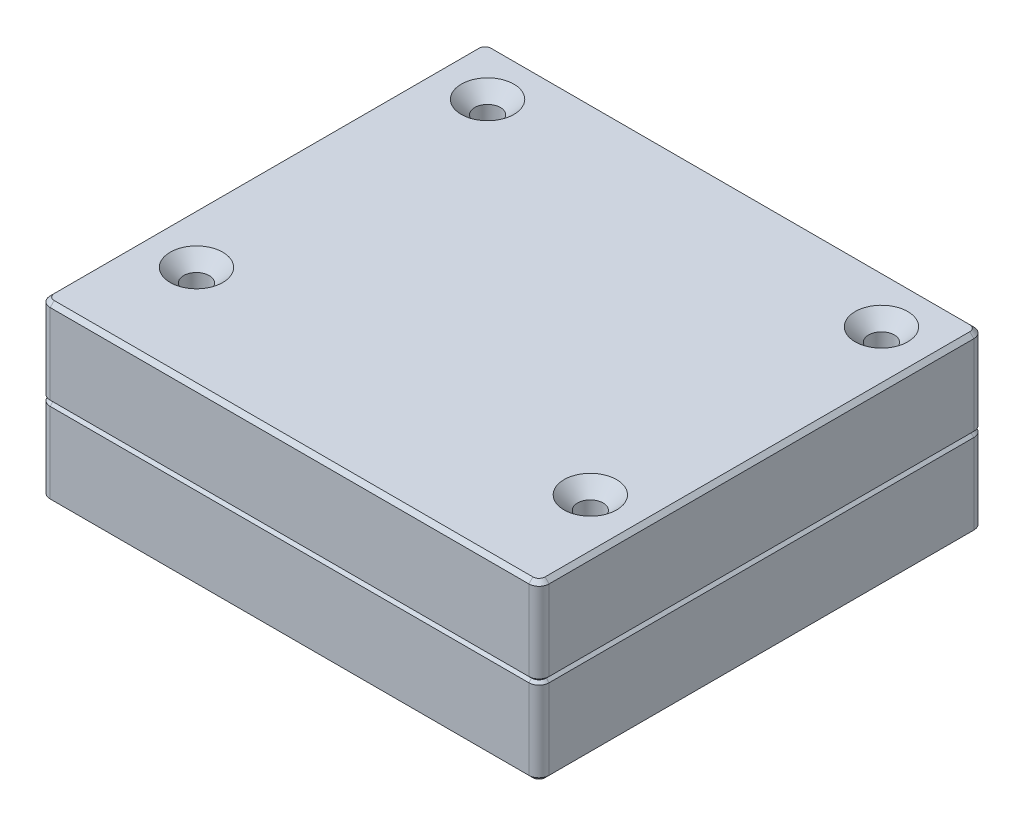
from build123d import *

# Parameters (mm, degrees)
BOSS_EXTRUDE1_DEPTH             = 2
BOSS_EXTRUDE2_DEPTH             = 1
BOSS_EXTRUDE4_START             = -2
BOSS_EXTRUDE4_DEPTH             = 1
SKETCH3_W                       = 70
SKETCH3_H                       = 64
BOSS_EXTRUDE5_DEPTH             = 2
BOSS_EXTRUDE6_REACH             = 74.888
BOSS_EXTRUDE6_DIRECTION_2_REACH = 74.888
SKETCH5_W                       = 15.58
SKETCH5_H                       = 6.82
SKETCH5_R                       = 1.4
BOSS_EXTRUDE8_DEPTH             = 9.996248688
FILLET1_R                       = 3
FILLET2_R                       = 2
FILLET4_R                       = 2
FILLET5_R                       = 1
FILLET6_R                       = 1.5
CHAMFER1_SIZE                   = 0.6
FILLET7_R                       = 1
CUT_EXTRUDE1_DEPTH              = 0.2
CUT_EXTRUDE2_DEPTH              = 0.2
SKETCH9_R                       = 1.9
CUT_EXTRUDE3_DEPTH              = 77.054825474
CHAMFER2_SIZE                   = 2
CHAMFER3_SIZE                   = 0.8
CHAMFER4_SIZE                   = 0.8
CHAMFER5_SIZE                   = 0.4
CHAMFER6_SIZE                   = 0.4


with BuildPart() as part:
    # Sketch1 → Boss-Extrude1 (new body)
    with BuildSketch(Plane.XY):
        Polygon((17.693293109, 0), (20.693293109, 0), (20.693293109, -10.896248688), (-20.693293109, -10.896248688), (-20.693293109, 0), (-17.693293109, 0), (-17.693293109, -9.896248688), (17.693293109, -9.896248688), align=None)
    extrude(amount=BOSS_EXTRUDE1_DEPTH)

    # Sketch2 → Boss-Extrude2 (add)
    with BuildSketch(Plane.XY.offset(2)):
        Polygon((-17.693293109, 0), (-16.693293109, 0), (-16.693293109, -8.896248688), (16.693293109, -8.896248688), (16.693293109, 0), (17.693293109, 0), (20.693293109, 0), (20.693293109, -10.896248688), (-20.693293109, -10.896248688), (-20.693293109, 0), align=None)
    extrude(amount=BOSS_EXTRUDE2_DEPTH)

    # Sketch2_3 → Boss-Extrude4 (add)
    with BuildSketch(Plane.XY.offset(2).offset(BOSS_EXTRUDE4_START)):
        Polygon((-16.693293109, 0), (-17.693293109, 0), (-17.693293109, -9.896248688), (17.693293109, -9.896248688), (17.693293109, 0), (16.693293109, 0), (16.693293109, -8.896248688), (-16.693293109, -8.896248688), align=None)
        Polygon((-17.693293109, -9.896248688), (-17.693293109, 0), (-20.693293109, 0), (-20.693293109, -10.896248688), (20.693293109, -10.896248688), (20.693293109, 0), (17.693293109, 0), (17.693293109, -9.896248688), align=None)
    extrude(amount=-BOSS_EXTRUDE4_DEPTH)

    # Sketch3 → Boss-Extrude5 (add)
    with BuildSketch(Plane.XZ.offset(10.896248688)):
        with Locations((0, 31)):
            Rectangle(SKETCH3_W, SKETCH3_H)
    extrude(amount=BOSS_EXTRUDE5_DEPTH)

    # Boss-Extrude6: up to this face of the body (flat: up to its plane)
    boss_extrude6_end = Plane(part.part.faces().sort_by_distance((18.907578824, 0, 1))[0])
    # Sketch4 → Boss-Extrude6 (add, up to the picked face)
    with BuildSketch(Plane(origin=(0, -10.896248688, 0), x_dir=(1, 0, 0), z_dir=(0, 1, 0)), mode=Mode.PRIVATE) as boss_extrude6_sk1:
        Polygon((20.693293109, 1), (37, 1), (37, -65), (-37, -65), (-37, 1), (-20.693293109, 1), (-20.693293109, -3), (-35, -3), (-35, -63), (35, -63), (35, -3), (20.693293109, -3), align=None)
    boss_extrude6_tool1 = split(extrude(boss_extrude6_sk1.sketch, amount=BOSS_EXTRUDE6_REACH, mode=Mode.PRIVATE), bisect_by=boss_extrude6_end, keep=Keep.BOTH, mode=Mode.PRIVATE)
    add(boss_extrude6_tool1.solids().sort_by(Axis((28.846647, -10.896249, -0.008436), (0, 1, 0)))[0])

    # Boss-Extrude6 direction 2: up to this face of the body (flat: up to its plane)
    boss_extrude6_direction_2_end = Plane(part.part.faces().sort_by_distance((0, -12.896248688, 31))[0])
    # Sketch4 → Boss-Extrude6 direction 2 (add, up to the picked face)
    with BuildSketch(Plane(origin=(0, -10.896248688, 0), x_dir=(1, 0, 0), z_dir=(0, 1, 0)), mode=Mode.PRIVATE) as boss_extrude6_direction_2_sk1:
        Polygon((20.693293109, 1), (37, 1), (37, -65), (-37, -65), (-37, 1), (-20.693293109, 1), (-20.693293109, -3), (-35, -3), (-35, -63), (35, -63), (35, -3), (20.693293109, -3), align=None)
    boss_extrude6_direction_2_tool1 = split(extrude(boss_extrude6_direction_2_sk1.sketch, amount=-BOSS_EXTRUDE6_DIRECTION_2_REACH, mode=Mode.PRIVATE), bisect_by=boss_extrude6_direction_2_end, keep=Keep.BOTH, mode=Mode.PRIVATE)
    add(boss_extrude6_direction_2_tool1.solids().sort_by(Axis((28.846647, -10.896249, -0.008436), (0, -1, 0)))[0])

    # Sketch5 → Boss-Extrude8 (add)
    with BuildSketch(Plane(origin=(0, -10.896248688, 0), x_dir=(1, 0, 0), z_dir=(0, 1, 0))):
        with Locations((29.21, -6.41)):
            Rectangle(SKETCH5_W, SKETCH5_H)
        with Locations((29.21, -6.41)):
            Circle(SKETCH5_R, mode=Mode.SUBTRACT)
        with Locations((29.21, -49.59)):
            Rectangle(SKETCH5_W, SKETCH5_H)
        with Locations((29.21, -49.59)):
            Circle(SKETCH5_R, mode=Mode.SUBTRACT)
    boss_extrude8 = extrude(amount=BOSS_EXTRUDE8_DEPTH)

    # Mirror3: Boss-Extrude8 across plane
    add(boss_extrude8.mirror(Plane(origin=(0, 0, 0), x_dir=(0, 0, 1), z_dir=(1, 0, 0))))

    # Fillet1
    fillet1_edges = [part.edges().sort_by_distance(p)[0] for p in [
        (21.42, -5.898124344, 9.82),
        (21.42, -5.898124344, 53),
        (21.42, -5.898124344, 46.18),
        (-21.42, -5.898124344, 9.82),
        (-21.42, -5.898124344, 46.18),
        (-21.42, -5.898124344, 53),
    ]]
    fillet(fillet1_edges, radius=FILLET1_R)

    # Fillet2
    fillet2_edges = [part.edges().sort_by_distance(p)[0] for p in [
        (35, -5.898124344, 9.82),
        (35, -5.898124344, 46.18),
        (35, -5.898124344, 53),
        (-35, -5.898124344, 9.82),
        (-35, -5.898124344, 46.18),
        (-35, -5.898124344, 53),
    ]]
    fillet(fillet2_edges, radius=FILLET2_R)

    # Fillet4
    fillet4_edges = [part.edges().sort_by_distance(p)[0] for p in [
        (-35, -5.448124344, 63),
        (35, -5.448124344, 63),
    ]]
    fillet(fillet4_edges, radius=FILLET4_R)

    # Fillet5
    fillet5_edges = [part.edges().sort_by_distance(p)[0] for p in [
        (16.693293109, -8.896248688, 2.5),
        (-16.693293109, -8.896248688, 2.5),
        (-16.693293109, -8.896248688, -0.5),
        (16.693293109, -8.896248688, -0.5),
    ]]
    fillet(fillet5_edges, radius=FILLET5_R)

    # Fillet6
    fillet6_edges = [part.edges().sort_by_distance(p)[0] for p in [
        (37, -6.448124344, -1),
        (37, -6.448124344, 65),
        (-37, -6.448124344, 65),
        (-37, -6.448124344, -1),
    ]]
    fillet(fillet6_edges, radius=FILLET6_R)

    # Chamfer1
    chamfer1_edges = [part.edges().sort_by_distance(p)[0] for p in [
        (0, -12.896248688, -1),
        (-37, -12.896248688, 32),
        (37, -12.896248688, 32),
        (0, -12.896248688, 65),
        (-36.560660172, -12.896248688, -0.560660172),
        (-36.560660172, -12.896248688, 64.560660172),
        (36.560660172, -12.896248688, 64.560660172),
        (36.560660172, -12.896248688, -0.560660172),
    ]]
    chamfer(chamfer1_edges, length=CHAMFER1_SIZE)

    # Fillet7
    fillet7_edges = [part.edges().sort_by_distance(p)[0] for p in [
        (21.42, -10.896248688, 4.91),
        (-21.42, -10.896248688, 4.91),
        (-28.71, -10.896248688, 9.82),
        (-21.42, -10.896248688, 49.59),
        (-28.71, -10.896248688, 53),
        (28.71, -10.896248688, 9.82),
        (28.71, -10.896248688, 53),
        (21.42, -10.896248688, 49.59),
        (-22.298679656, -10.896248688, 8.941320344),
        (-22.298679656, -10.896248688, 52.121320344),
        (-22.298679656, -10.896248688, 47.058679656),
        (22.298679656, -10.896248688, 8.941320344),
        (22.298679656, -10.896248688, 52.121320344),
        (22.298679656, -10.896248688, 47.058679656),
        (-35, -10.896248688, 28),
        (-28.71, -10.896248688, 46.18),
        (35, -10.896248688, 58),
        (28.71, -10.896248688, 46.18),
        (35, -10.896248688, 28),
        (34.414213562, -10.896248688, 10.405786438),
        (34.414213562, -10.896248688, 45.594213562),
        (34.414213562, -10.896248688, 53.585786438),
        (-34.414213562, -10.896248688, 10.405786438),
        (-34.414213562, -10.896248688, 45.594213562),
        (-34.414213562, -10.896248688, 53.585786438),
        (-35, -10.896248688, 58),
        (0, -10.896248688, 63),
        (34.414213562, -10.896248688, 62.414213562),
        (-34.414213562, -10.896248688, 62.414213562),
    ]]
    fillet(fillet7_edges, radius=FILLET7_R)


with BuildPart() as body_2:
    # Mirror4: mirrored copy
    add(part.part.mirror(Plane.ZX))

    # Sketch8 → Cut-Extrude2 (cut)
    with BuildSketch(Plane.XZ.offset(-10.896248688)):
        Polygon((-17.856905846, 13.437302516), (-17.856905846, 16.668071747), (-16.77998277, 16.668071747), (-16.77998277, 15.59114867), (-11.856905846, 15.59114867), (-11.856905846, 14.514225593), (-16.77998277, 14.514225593), (-16.77998277, 13.437302516), align=None)
        with BuildLine():
            add(Edge.make_bspline(
                [(-18.010752, 21.603167901), (-18.008050512, 21.707484931), (-18.002717161, 21.913430376), (-17.958275747, 22.216307404), (-17.885824456, 22.508163693), (-17.785254831, 22.788970316), (-17.653307909, 23.0574515), (-17.496033953, 23.316223934), (-17.306596788, 23.562010122), (-17.091743359, 23.793960914), (-16.857947533, 24.008257244), (-16.606233441, 24.19389776), (-16.34291732, 24.352639042), (-16.06700126, 24.483233398), (-15.777544563, 24.583547586), (-15.475753411, 24.65363426), (-15.161546068, 24.698718975), (-14.947607117, 24.703900089), (-14.838877, 24.706533285)],
                knots=[0, 0, 0, 0, 1.014235534, 2.002330665, 2.970116157, 3.9352621, 4.897279957, 5.875024536, 6.875755618, 7.909865842, 8.947091691, 9.955591861, 10.946663836, 11.933282567, 12.91916997, 13.920121047, 14.942943865, 16, 16, 16, 16], degree=3))
            add(Edge.make_bspline(
                [(-14.838877, 24.706533285), (-14.731372357, 24.703728135), (-14.519531007, 24.698200496), (-14.208214407, 24.655483535), (-13.909673698, 24.584171783), (-13.623302062, 24.485832125), (-13.350543528, 24.357378178), (-13.090259563, 24.201352816), (-12.843342843, 24.016112425), (-12.610833804, 23.806095379), (-12.398346893, 23.576316348), (-12.21231631, 23.331582559), (-12.054717653, 23.074810639), (-11.924936358, 22.80620169), (-11.827035463, 22.523820109), (-11.753826534, 22.230853406), (-11.711477209, 21.924918773), (-11.70589375, 21.717077578), (-11.703059693, 21.611581362)],
                knots=[0, 0, 0, 0, 1.051628416, 2.072267533, 3.067761847, 4.050852917, 5.029392597, 6.012272624, 7.015026456, 8.044749159, 9.073964344, 10.072810436, 11.047668484, 12.017263184, 12.98554948, 13.966731695, 14.967951888, 16, 16, 16, 16], degree=3))
            add(Edge.make_bspline(
                [(-11.703059693, 21.611581362), (-11.705572491, 21.501236656), (-11.710509798, 21.28442439), (-11.757065253, 20.967039905), (-11.828045244, 20.663391525), (-11.930807193, 20.374311255), (-12.064332038, 20.100023822), (-12.225553099, 19.839299163), (-12.417584582, 19.594098159), (-12.634634491, 19.365238138), (-12.87219629, 19.157914557), (-13.12314328, 18.974904518), (-13.385577697, 18.820533075), (-13.659617354, 18.694792298), (-13.943560469, 18.595663425), (-14.23913599, 18.525739242), (-14.545635114, 18.484433365), (-14.753815442, 18.478679695), (-14.859309693, 18.475764055)],
                knots=[0, 0, 0, 0, 1.067953136, 2.098381936, 3.099641766, 4.083805132, 5.062469929, 6.048665414, 7.046702845, 8.073106546, 9.098695993, 10.09591865, 11.076726721, 12.041940862, 13.011263376, 13.984305721, 14.978557872, 16, 16, 16, 16], degree=3))
            add(Edge.make_bspline(
                [(-14.859309693, 18.475764055), (-14.9302806, 18.476679418), (-15.071323759, 18.478498555), (-15.280344328, 18.500401634), (-15.485278024, 18.531956053), (-15.685341068, 18.578548042), (-15.882181674, 18.6355154), (-16.074046211, 18.708357935), (-16.262235824, 18.792340607), (-16.444641289, 18.889440532), (-16.619161572, 18.999212413), (-16.787297002, 19.11643751), (-16.94464736, 19.245579419), (-17.092890877, 19.383998884), (-17.231459708, 19.532158592), (-17.360209812, 19.690357225), (-17.480614714, 19.857458479), (-17.591075987, 20.033477718), (-17.688717297, 20.217113033), (-17.776155603, 20.404312192), (-17.847934677, 20.595853118), (-17.907032894, 20.790613298), (-17.954525483, 20.988317482), (-17.986089046, 21.190537055), (-18.007983411, 21.395553289), (-18.009826947, 21.533798793), (-18.010752, 21.603167901)],
                knots=[0, 0, 0, 0, 1.034634222, 2.056167603, 3.061938024, 4.056975325, 5.049831446, 6.048294015, 7.047371884, 8.053753139, 9.058980286, 10.052730068, 11.041053953, 12.024946181, 13.008838409, 13.997162294, 14.997691456, 16.01096975, 17.025258359, 18.029177048, 19.022170708, 20.005507574, 20.996177714, 21.984639769, 22.988728483, 24, 24, 24, 24], degree=3))
        make_face()
        with BuildLine():
            add(Edge.make_bspline(
                [(-16.933828923, 21.586340978), (-16.93194515, 21.516135413), (-16.928227337, 21.377577721), (-16.899902623, 21.174338821), (-16.854664835, 20.9792223), (-16.789138452, 20.793309765), (-16.705739998, 20.615795456), (-16.604760876, 20.446364694), (-16.482730042, 20.287363746), (-16.346198787, 20.136672487), (-16.194071593, 20.000547731), (-16.031041432, 19.880277215), (-15.857380563, 19.779630165), (-15.674702254, 19.69533763), (-15.480952335, 19.631884033), (-15.27764847, 19.586687939), (-15.064440358, 19.558125694), (-14.919096665, 19.554525388), (-14.844886616, 19.552687132)],
                knots=[0, 0, 0, 0, 1.033739768, 2.040188636, 3.016340934, 3.979330865, 4.937572243, 5.900995986, 6.878200029, 7.884839167, 8.891893314, 9.879764717, 10.863503415, 11.843163062, 12.837761627, 13.859916423, 14.907309254, 16, 16, 16, 16], degree=3))
            add(Edge.make_bspline(
                [(-14.844886616, 19.552687132), (-14.762647564, 19.555129971), (-14.601472648, 19.559917531), (-14.366314821, 19.593447637), (-14.144021802, 19.651325762), (-13.935697322, 19.73340453), (-13.74016809, 19.83743132), (-13.55853596, 19.964849558), (-13.389946766, 20.115638655), (-13.291491535, 20.231740947), (-13.241521231, 20.290667901)],
                knots=[0, 0, 0, 0, 1.078420897, 2.113526272, 3.107597235, 4.084297302, 5.043369457, 6.005430726, 6.9876695, 8, 8, 8, 8], degree=3))
            add(Edge.make_bspline(
                [(-13.241521231, 20.290667901), (-13.204606935, 20.338944378), (-13.131610028, 20.434409656), (-13.038049517, 20.586793024), (-12.957858825, 20.743717887), (-12.893065695, 20.90636844), (-12.842100508, 21.074401174), (-12.806410426, 21.247793045), (-12.784011813, 21.426298374), (-12.781334754, 21.547012043), (-12.77998277, 21.607975593)],
                knots=[0, 0, 0, 0, 1.023928204, 2.024787132, 3.009472467, 3.9914905, 4.972207045, 5.96565515, 6.972602802, 8, 8, 8, 8], degree=3))
            add(Edge.make_bspline(
                [(-12.77998277, 21.607975593), (-12.781885311, 21.676972559), (-12.78562862, 21.812726259), (-12.813564716, 22.012201934), (-12.861057115, 22.203212134), (-12.925524012, 22.387550617), (-13.012017908, 22.562662362), (-13.114201901, 22.731333074), (-13.237025077, 22.890622294), (-13.376433164, 23.040471874), (-13.529094947, 23.177918646), (-13.69217866, 23.299172658), (-13.86416685, 23.401475359), (-14.045031066, 23.485125132), (-14.234572538, 23.550650573), (-14.433371897, 23.595389356), (-14.640523401, 23.624169329), (-14.781487599, 23.627773903), (-14.853300077, 23.629610208)],
                knots=[0, 0, 0, 0, 1.026460056, 2.019592442, 2.989754624, 3.951362471, 4.919177453, 5.890456226, 6.881277895, 7.906300149, 8.932084862, 9.933608786, 10.925308803, 11.904168404, 12.893913482, 13.903284022, 14.931853825, 16, 16, 16, 16], degree=3))
            add(Edge.make_bspline(
                [(-14.853300077, 23.629610208), (-14.924702226, 23.627716893), (-15.065246467, 23.623990191), (-15.271828065, 23.595896132), (-15.469517635, 23.549190715), (-15.658824769, 23.483181033), (-15.840743315, 23.400946705), (-16.013694377, 23.297646699), (-16.177528322, 23.175520094), (-16.331271136, 23.036799466), (-16.472560404, 22.885835426), (-16.595171393, 22.723753897), (-16.70171707, 22.555097857), (-16.785180501, 22.375995484), (-16.851675679, 22.19011159), (-16.900643672, 21.99631176), (-16.928028354, 21.793862003), (-16.931878165, 21.656131246), (-16.933828923, 21.586340978)],
                knots=[0, 0, 0, 0, 1.055040155, 2.076685641, 3.074845078, 4.052329834, 5.035358467, 6.020382375, 7.023447318, 8.050688466, 9.077178457, 10.074336316, 11.0503314, 12.019748348, 12.988025369, 13.964577102, 14.968620271, 16, 16, 16, 16], degree=3))
        make_face(mode=Mode.SUBTRACT)
        with BuildLine():
            Line((-17.856905846, 27.052687132), (-17.856905846, 28.254610208))
            add(Edge.make_bspline(
                [(-17.856905846, 28.254610208), (-17.856554321, 28.333142304), (-17.855876154, 28.484647176), (-17.847652456, 28.70312966), (-17.83291513, 28.904690476), (-17.814702003, 29.089283196), (-17.789168323, 29.256832314), (-17.759894693, 29.407546372), (-17.72423501, 29.541460761), (-17.681894341, 29.660072336), (-17.632020011, 29.766555223), (-17.578748703, 29.867203978), (-17.515603815, 29.960503771), (-17.447136954, 30.048645013), (-17.371923727, 30.130960961), (-17.290261394, 30.208061592), (-17.200963164, 30.279152983), (-17.10464422, 30.343789437), (-17.00326555, 30.402456876), (-16.896595967, 30.453704147), (-16.78448026, 30.495275239), (-16.667640021, 30.530147605), (-16.546081349, 30.558157593), (-16.41905637, 30.576801893), (-16.287452096, 30.58946605), (-16.197882141, 30.590583487), (-16.152578923, 30.59114867)],
                knots=[0, 0, 0, 0, 1.698787518, 3.27731721, 4.728409951, 6.070286353, 7.288646904, 8.393455548, 9.389990496, 10.283725379, 11.113616976, 11.931887102, 12.744353494, 13.547053751, 14.344590688, 15.153907614, 15.974148981, 16.810666655, 17.660988447, 18.506082349, 19.367288142, 20.244738011, 21.142497992, 22.06302001, 23.020302899, 24, 24, 24, 24], degree=3))
            add(Edge.make_bspline(
                [(-16.152578923, 30.59114867), (-16.102461053, 30.59033092), (-16.00397328, 30.58872394), (-15.859602283, 30.572970366), (-15.721957627, 30.546058271), (-15.589878445, 30.510885616), (-15.465538034, 30.46183968), (-15.345968496, 30.405807587), (-15.234526205, 30.336868137), (-15.129802127, 30.258101849), (-15.031000911, 30.172050271), (-14.940767076, 30.076809437), (-14.859127574, 29.97350114), (-14.782551921, 29.864994404), (-14.717171511, 29.746818148), (-14.656185737, 29.62310931), (-14.604510712, 29.490753531), (-14.577387814, 29.398658023), (-14.563636616, 29.351965978)],
                knots=[0, 0, 0, 0, 1.101964615, 2.165495883, 3.188506962, 4.184641065, 5.166448333, 6.124117473, 7.085225874, 8.042124548, 9.003636759, 9.963451826, 10.9225791, 11.897800977, 12.880319672, 13.889154746, 14.929810112, 16, 16, 16, 16], degree=3))
            add(Edge.make_bspline(
                [(-14.563636616, 29.351965978), (-14.555983952, 29.321207885), (-14.539405819, 29.254575951), (-14.522574853, 29.144318401), (-14.507099815, 29.017258152), (-14.493800893, 28.872984334), (-14.484760725, 28.71141377), (-14.477700755, 28.532702902), (-14.472567429, 28.336770743), (-14.472385276, 28.200527266), (-14.472290462, 28.129610208)],
                knots=[0, 0, 0, 0, 0.618981996, 1.340914327, 2.176866532, 3.120127938, 4.170906482, 5.338178032, 6.614476169, 8, 8, 8, 8], degree=3))
            Line((-14.472290462, 28.129610208), (-11.856905846, 28.129610208))
            Line((-11.856905846, 28.129610208), (-11.856905846, 27.052687132))
            Line((-11.856905846, 27.052687132), (-17.856905846, 27.052687132))
        make_face()
        with BuildLine():
            Line((-15.549213539, 28.129610208), (-15.549213539, 28.510619824))
            add(Edge.make_bspline(
                [(-15.549213539, 28.510619824), (-15.549653078, 28.579950621), (-15.550461838, 28.707520318), (-15.562159664, 28.881734331), (-15.580021147, 29.0217394), (-15.605647689, 29.132337174), (-15.644513351, 29.219689827), (-15.689552284, 29.294940583), (-15.746418987, 29.360021216), (-15.812493656, 29.415176525), (-15.88692553, 29.459995096), (-15.969515179, 29.491499714), (-16.059084882, 29.511366514), (-16.121620905, 29.513254614), (-16.153780846, 29.514225593)],
                knots=[0, 0, 0, 0, 1.862197296, 3.426470689, 4.686743892, 5.65255712, 6.462325617, 7.244961981, 8.000258385, 8.771939908, 9.549006364, 10.32248703, 11.137317743, 12, 12, 12, 12], degree=3))
            add(Edge.make_bspline(
                [(-16.153780846, 29.514225593), (-16.181886018, 29.513285273), (-16.236416807, 29.511460826), (-16.315062909, 29.49787323), (-16.388233508, 29.476784587), (-16.454908627, 29.444554687), (-16.516643403, 29.405424652), (-16.571516016, 29.355783336), (-16.621301782, 29.298536696), (-16.64762099, 29.254265512), (-16.660992385, 29.23177367)],
                knots=[0, 0, 0, 0, 1.102449765, 2.139017612, 3.12397484, 4.080535277, 5.035673127, 5.982361139, 6.974944601, 8, 8, 8, 8], degree=3))
            add(Edge.make_bspline(
                [(-16.660992385, 29.23177367), (-16.670625037, 29.212726595), (-16.691019334, 29.172400035), (-16.714729197, 29.103719994), (-16.734731078, 29.024464275), (-16.751332445, 28.934097813), (-16.764216831, 28.832981106), (-16.774070163, 28.721132194), (-16.778032571, 28.598386482), (-16.779314774, 28.513024184), (-16.77998277, 28.468552516)],
                knots=[0, 0, 0, 0, 0.656809284, 1.390599849, 2.23162475, 3.173112763, 4.218524733, 5.370385145, 6.63003504, 8, 8, 8, 8], degree=3))
            Line((-16.77998277, 28.468552516), (-16.77998277, 28.129610208))
            Line((-16.77998277, 28.129610208), (-15.549213539, 28.129610208))
        make_face(mode=Mode.SUBTRACT)
    extrude(amount=-CUT_EXTRUDE2_DEPTH, mode=Mode.SUBTRACT)

    # Sketch9 → Cut-Extrude3 (cut, through all)
    with BuildSketch(Plane.XZ.offset(-0.9)):
        with Locations((-29.21, 6.41)):
            Circle(SKETCH9_R)
        with Locations((-29.21, 49.59)):
            Circle(SKETCH9_R)
        with Locations((29.21, 49.59)):
            Circle(SKETCH9_R)
        with Locations((29.21, 6.41)):
            Circle(SKETCH9_R)
    extrude(amount=-CUT_EXTRUDE3_DEPTH, mode=Mode.SUBTRACT)

    # Chamfer2
    chamfer2_edges = [body_2.edges().sort_by_distance(p)[0] for p in [
        (-31.11, 12.896248688, 6.41),
        (-31.11, 12.896248688, 49.59),
        (27.31, 12.896248688, 49.59),
        (27.31, 12.896248688, 6.41),
    ]]
    chamfer(chamfer2_edges, length=CHAMFER2_SIZE)

    # Chamfer6
    chamfer6_edges = [body_2.edges().sort_by_distance(p)[0] for p in [
        (17.693293109, 0, 1),
        (-17.693293109, 0, 1),
        (17.193293109, 0, 2),
        (16.693293109, 0, 2.5),
        (-17.193293109, 0, 2),
        (-16.693293109, 0, 2.5),
        (25.846646555, 0, 3),
        (-25.846646555, 0, 3),
        (0, 0, 63),
        (35, 0, 32),
        (-34.414213562, 0, 62.414213562),
        (34.414213562, 0, 62.414213562),
        (-26.096646555, 0, -1),
        (37, 0, 32),
        (-37, 0, 32),
        (0, 0, 65),
        (-36.560660172, 0, -0.560660172),
        (-36.560660172, 0, 64.560660172),
        (36.560660172, 0, 64.560660172),
        (36.560660172, 0, -0.560660172),
        (-16.693293109, 0, -0.5),
        (17.193293109, 0, 0),
        (16.693293109, 0, -0.5),
        (-17.193293109, 0, 0),
        (26.096646555, 0, -1),
        (-35, 0, 32),
    ]]
    chamfer(chamfer6_edges, length=CHAMFER6_SIZE)


with BuildPart() as part_1:
    add(part.part)

    # Sketch7 → Cut-Extrude1 (cut)
    with BuildSketch(Plane(origin=(0, -10.896248688, 0), x_dir=(1, 0, 0), z_dir=(0, 1, 0))):
        with BuildLine():
            Line((-11.856905846, -51.937302516), (-17.856905846, -51.937302516))
            Line((-17.856905846, -51.937302516), (-17.856905846, -50.975764055))
            add(Edge.make_bspline(
                [(-17.856905846, -50.975764055), (-17.856913529, -50.90845035), (-17.856928393, -50.778199608), (-17.850329336, -50.590281779), (-17.841792717, -50.416003864), (-17.832242224, -50.25592048), (-17.815784818, -50.109759157), (-17.798440509, -49.977742155), (-17.777524342, -49.859605704), (-17.758761891, -49.786568356), (-17.749934693, -49.752206362)],
                knots=[0, 0, 0, 0, 1.311965854, 2.538629056, 3.664479157, 4.713267157, 5.663616078, 6.530575999, 7.308677837, 8, 8, 8, 8], degree=3))
            add(Edge.make_bspline(
                [(-17.749934693, -49.752206362), (-17.73748328, -49.70708597), (-17.71304961, -49.618545276), (-17.663713694, -49.491720051), (-17.608839953, -49.371434422), (-17.546361158, -49.257714582), (-17.475111928, -49.151905866), (-17.396451766, -49.052556393), (-17.310352024, -48.960133746), (-17.216310228, -48.876090881), (-17.116775248, -48.800291285), (-17.011805179, -48.733950005), (-16.902547776, -48.677355492), (-16.788770273, -48.631143125), (-16.670614924, -48.596668318), (-16.548456081, -48.571388838), (-16.421852992, -48.555020472), (-16.335722801, -48.553472767), (-16.292002, -48.552687132)],
                knots=[0, 0, 0, 0, 1.099825721, 2.158211141, 3.195041695, 4.206926465, 5.204905297, 6.190538631, 7.183526201, 8.170733634, 9.152262494, 10.121785545, 11.086538014, 12.041584943, 13.004265891, 13.975982849, 14.972582673, 16, 16, 16, 16], degree=3))
            add(Edge.make_bspline(
                [(-16.292002, -48.552687132), (-16.235829392, -48.554734933), (-16.125260513, -48.55876578), (-15.962900111, -48.584663672), (-15.809622593, -48.632676459), (-15.662730572, -48.697044833), (-15.52131994, -48.782042202), (-15.387147435, -48.891943643), (-15.255580635, -49.022696704), (-15.176753331, -49.123073286), (-15.135752, -49.175283285)],
                knots=[0, 0, 0, 0, 0.986208652, 1.941230559, 2.875571179, 3.798165321, 4.751009532, 5.761494368, 6.83566093, 8, 8, 8, 8], degree=3))
            add(Edge.make_bspline(
                [(-15.135752, -49.175283285), (-15.114159011, -49.132978081), (-15.071821133, -49.050029281), (-15.002190003, -48.932303208), (-14.928280557, -48.823163225), (-14.851061117, -48.722975581), (-14.769372995, -48.631122642), (-14.683484542, -48.54907164), (-14.593816361, -48.474707804), (-14.499751094, -48.409492389), (-14.400806284, -48.353276612), (-14.298432374, -48.303818449), (-14.191720061, -48.261240639), (-14.080437868, -48.226641577), (-13.964726651, -48.199944295), (-13.844854329, -48.182803102), (-13.720977425, -48.169613827), (-13.636590961, -48.168591532), (-13.593684693, -48.168071747)],
                knots=[0, 0, 0, 0, 1.164539168, 2.28333912, 3.351515688, 4.395009163, 5.383055728, 6.362812631, 7.305003804, 8.237049474, 9.165619381, 10.092784925, 11.02322402, 11.98030579, 12.947919037, 13.931657808, 14.948352129, 16, 16, 16, 16], degree=3))
            add(Edge.make_bspline(
                [(-13.593684693, -48.168071747), (-13.511734894, -48.17144852), (-13.350007295, -48.178112567), (-13.112589405, -48.226955804), (-12.887687777, -48.311181575), (-12.67648769, -48.425363745), (-12.484166124, -48.565352452), (-12.314317751, -48.72545232), (-12.17161003, -48.906146585), (-12.075168616, -49.072354962), (-12.010553586, -49.21618454), (-11.970420773, -49.335271154), (-11.933977416, -49.463397893), (-11.905461424, -49.602018873), (-11.884271036, -49.750183812), (-11.868816237, -49.907794212), (-11.859073505, -50.075402625), (-11.857643008, -50.190493925), (-11.856905846, -50.249802516)],
                knots=[0, 0, 0, 0, 1.284195246, 2.534354168, 3.78027825, 5.036354521, 6.286276797, 7.499025881, 8.683874548, 9.882754589, 10.501292686, 11.152751137, 11.850656415, 12.588451682, 13.369156733, 14.195917516, 15.070324243, 16, 16, 16, 16], degree=3))
            Line((-11.856905846, -50.249802516), (-11.856905846, -51.937302516))
        make_face()
        with BuildLine():
            Line((-16.77998277, -50.860379439), (-15.472290462, -50.860379439))
            Line((-15.472290462, -50.860379439), (-15.472290462, -50.574321747))
            add(Edge.make_bspline(
                [(-15.472290462, -50.574321747), (-15.472629491, -50.535443936), (-15.473283966, -50.460392676), (-15.481713382, -50.351989092), (-15.496094489, -50.251191264), (-15.516159751, -50.158381499), (-15.541639708, -50.072695239), (-15.572297583, -49.994679873), (-15.609703523, -49.924678419), (-15.665421322, -49.843352921), (-15.747412558, -49.757386005), (-15.865865885, -49.681710296), (-16.002086761, -49.637137808), (-16.09816027, -49.632173635), (-16.147771231, -49.629610208)],
                knots=[0, 0, 0, 0, 1.065314748, 2.056525647, 2.977365736, 3.853934255, 4.656397591, 5.425096493, 6.14721249, 6.826394842, 8.123232004, 9.372140726, 10.643011755, 12, 12, 12, 12], degree=3))
            add(Edge.make_bspline(
                [(-16.147771231, -49.629610208), (-16.194240256, -49.631661387), (-16.284086247, -49.635627257), (-16.410236096, -49.680506465), (-16.522038148, -49.750210392), (-16.598533528, -49.832513113), (-16.650834525, -49.910000014), (-16.685099282, -49.97639917), (-16.716445059, -50.04896852), (-16.737588279, -50.130320511), (-16.75781595, -50.217847556), (-16.770051597, -50.313242712), (-16.77910474, -50.415491591), (-16.779683815, -50.486157134), (-16.77998277, -50.522639055)],
                knots=[0, 0, 0, 0, 1.348076466, 2.606451671, 3.849585156, 5.153713056, 5.843081946, 6.568636199, 7.327130502, 8.139792284, 9.011860696, 9.942616599, 10.937851541, 12, 12, 12, 12], degree=3))
            Line((-16.77998277, -50.522639055), (-16.77998277, -50.860379439))
        make_face(mode=Mode.SUBTRACT)
        with BuildLine():
            Line((-14.472290462, -50.860379439), (-12.933828923, -50.860379439))
            Line((-12.933828923, -50.860379439), (-12.933828923, -50.550283285))
            add(Edge.make_bspline(
                [(-12.933828923, -50.550283285), (-12.934185471, -50.488978389), (-12.934870979, -50.371112074), (-12.942924158, -50.202244824), (-12.957860675, -50.048785477), (-12.975299779, -49.910697922), (-13.002873885, -49.789112436), (-13.031543855, -49.681808457), (-13.068421496, -49.59064539), (-13.11118635, -49.514067471), (-13.159561062, -49.450022453), (-13.211914934, -49.394563886), (-13.270414966, -49.348307295), (-13.333767076, -49.311106698), (-13.401386687, -49.279856718), (-13.475518335, -49.260713667), (-13.553856626, -49.246207015), (-13.60803334, -49.245405107), (-13.635752, -49.244994824)],
                knots=[0, 0, 0, 0, 1.753677247, 3.371663338, 4.833688836, 6.164395063, 7.349095089, 8.3975697, 9.338276771, 10.154261968, 10.899224605, 11.628775934, 12.330426574, 13.024264642, 13.727131073, 14.452891561, 15.208446408, 16, 16, 16, 16], degree=3))
            add(Edge.make_bspline(
                [(-13.635752, -49.244994824), (-13.667450387, -49.245895294), (-13.729190317, -49.247649168), (-13.819415455, -49.262015799), (-13.903701149, -49.288015859), (-13.984262777, -49.321251403), (-14.058794421, -49.366212824), (-14.128429844, -49.420976135), (-14.191485478, -49.486518734), (-14.251647506, -49.560380476), (-14.304758949, -49.646110403), (-14.348757025, -49.74515014), (-14.387461615, -49.856000385), (-14.417753823, -49.980521601), (-14.443643931, -50.117601036), (-14.459060042, -50.268363674), (-14.47054077, -50.43151625), (-14.471693979, -50.544650571), (-14.472290462, -50.603167901)],
                knots=[0, 0, 0, 0, 0.844975127, 1.645784239, 2.426462591, 3.192310282, 3.963577212, 4.739343514, 5.547598874, 6.383408773, 7.27567655, 8.226932621, 9.267447238, 10.402227125, 11.640487588, 12.984111775, 14.440069075, 16, 16, 16, 16], degree=3))
            Line((-14.472290462, -50.603167901), (-14.472290462, -50.860379439))
        make_face(mode=Mode.SUBTRACT)
        with BuildLine():
            add(Edge.make_bspline(
                [(-18.010752, -43.002206362), (-18.008050512, -42.897889332), (-18.002717161, -42.691943887), (-17.958275747, -42.389066859), (-17.885824456, -42.09721057), (-17.785254831, -41.816403947), (-17.653307909, -41.547922763), (-17.496033953, -41.289150329), (-17.306596788, -41.043364141), (-17.091743359, -40.811413349), (-16.857947533, -40.597117019), (-16.606233441, -40.411476504), (-16.34291732, -40.252735222), (-16.06700126, -40.122140865), (-15.777544563, -40.021826677), (-15.475753411, -39.951740003), (-15.161546068, -39.906655288), (-14.947607117, -39.901474174), (-14.838877, -39.898840978)],
                knots=[0, 0, 0, 0, 1.014235534, 2.002330665, 2.970116157, 3.9352621, 4.897279957, 5.875024536, 6.875755618, 7.909865842, 8.947091691, 9.955591861, 10.946663836, 11.933282567, 12.91916997, 13.920121047, 14.942943865, 16, 16, 16, 16], degree=3))
            add(Edge.make_bspline(
                [(-14.838877, -39.898840978), (-14.731372357, -39.901646128), (-14.519531007, -39.907173767), (-14.208214407, -39.949890728), (-13.909673698, -40.02120248), (-13.623302062, -40.119542139), (-13.350543528, -40.247996085), (-13.090259563, -40.404021447), (-12.843342843, -40.589261838), (-12.610833804, -40.799278884), (-12.398346893, -41.029057915), (-12.21231631, -41.273791704), (-12.054717653, -41.530563624), (-11.924936358, -41.799172573), (-11.827035463, -42.081554155), (-11.753826534, -42.374520857), (-11.711477209, -42.68045549), (-11.70589375, -42.888296685), (-11.703059693, -42.993792901)],
                knots=[0, 0, 0, 0, 1.051628416, 2.072267533, 3.067761847, 4.050852917, 5.029392597, 6.012272624, 7.015026456, 8.044749159, 9.073964344, 10.072810436, 11.047668484, 12.017263184, 12.98554948, 13.966731695, 14.967951888, 16, 16, 16, 16], degree=3))
            add(Edge.make_bspline(
                [(-11.703059693, -42.993792901), (-11.705572491, -43.104137607), (-11.710509798, -43.320949873), (-11.757065253, -43.638334358), (-11.828045244, -43.941982738), (-11.930807193, -44.231063008), (-12.064332038, -44.505350441), (-12.225553099, -44.7660751), (-12.417584582, -45.011276104), (-12.634634491, -45.240136125), (-12.87219629, -45.447459706), (-13.12314328, -45.630469745), (-13.385577697, -45.784841188), (-13.659617354, -45.910581965), (-13.943560469, -46.009710838), (-14.23913599, -46.079635021), (-14.545635114, -46.120940898), (-14.753815442, -46.126694568), (-14.859309693, -46.129610208)],
                knots=[0, 0, 0, 0, 1.067953136, 2.098381936, 3.099641766, 4.083805132, 5.062469929, 6.048665414, 7.046702845, 8.073106546, 9.098695993, 10.09591865, 11.076726721, 12.041940862, 13.011263376, 13.984305721, 14.978557872, 16, 16, 16, 16], degree=3))
            add(Edge.make_bspline(
                [(-14.859309693, -46.129610208), (-14.9302806, -46.128694845), (-15.071323759, -46.126875708), (-15.280344328, -46.104972629), (-15.485278024, -46.07341821), (-15.685341068, -46.026826221), (-15.882181674, -45.969858864), (-16.074046211, -45.897016328), (-16.262235824, -45.813033656), (-16.444641289, -45.715933731), (-16.619161572, -45.60616185), (-16.787297002, -45.488936753), (-16.94464736, -45.359794844), (-17.092890877, -45.221375379), (-17.231459708, -45.073215672), (-17.360209812, -44.915017038), (-17.480614714, -44.747915784), (-17.591075987, -44.571896545), (-17.688717297, -44.38826123), (-17.776155603, -44.201062071), (-17.847934677, -44.009521146), (-17.907032894, -43.814760965), (-17.954525483, -43.617056781), (-17.986089046, -43.414837209), (-18.007983411, -43.209820974), (-18.009826947, -43.07157547), (-18.010752, -43.002206362)],
                knots=[0, 0, 0, 0, 1.034634222, 2.056167603, 3.061938024, 4.056975325, 5.049831446, 6.048294015, 7.047371884, 8.053753139, 9.058980286, 10.052730068, 11.041053953, 12.024946181, 13.008838409, 13.997162294, 14.997691456, 16.01096975, 17.025258359, 18.029177048, 19.022170708, 20.005507574, 20.996177714, 21.984639769, 22.988728483, 24, 24, 24, 24], degree=3))
        make_face()
        with BuildLine():
            add(Edge.make_bspline(
                [(-16.933828923, -43.019033285), (-16.93194515, -43.08923885), (-16.928227337, -43.227796542), (-16.899902623, -43.431035442), (-16.854664835, -43.626151964), (-16.789138452, -43.812064498), (-16.705739998, -43.989578808), (-16.604760876, -44.159009569), (-16.482730042, -44.318010517), (-16.346198787, -44.468701776), (-16.194071593, -44.604826532), (-16.031041432, -44.725097048), (-15.857380563, -44.825744098), (-15.674702254, -44.910036633), (-15.480952335, -44.97349023), (-15.27764847, -45.018686324), (-15.064440358, -45.047248569), (-14.919096665, -45.050848876), (-14.844886616, -45.052687132)],
                knots=[0, 0, 0, 0, 1.033739768, 2.040188636, 3.016340934, 3.979330865, 4.937572243, 5.900995986, 6.878200029, 7.884839167, 8.891893314, 9.879764717, 10.863503415, 11.843163062, 12.837761627, 13.859916423, 14.907309254, 16, 16, 16, 16], degree=3))
            add(Edge.make_bspline(
                [(-14.844886616, -45.052687132), (-14.762647564, -45.050244292), (-14.601472648, -45.045456733), (-14.366314821, -45.011926626), (-14.144021802, -44.954048501), (-13.935697322, -44.871969734), (-13.74016809, -44.767942943), (-13.55853596, -44.640524705), (-13.389946766, -44.489735609), (-13.291491535, -44.373633316), (-13.241521231, -44.314706362)],
                knots=[0, 0, 0, 0, 1.078420897, 2.113526272, 3.107597235, 4.084297302, 5.043369457, 6.005430726, 6.9876695, 8, 8, 8, 8], degree=3))
            add(Edge.make_bspline(
                [(-13.241521231, -44.314706362), (-13.204606935, -44.266429885), (-13.131610028, -44.170964607), (-13.038049517, -44.01858124), (-12.957858825, -43.861656377), (-12.893065695, -43.699005823), (-12.842100508, -43.53097309), (-12.806410426, -43.357581218), (-12.784011813, -43.179075889), (-12.781334754, -43.058362221), (-12.77998277, -42.99739867)],
                knots=[0, 0, 0, 0, 1.023928204, 2.024787132, 3.009472467, 3.9914905, 4.972207045, 5.96565515, 6.972602802, 8, 8, 8, 8], degree=3))
            add(Edge.make_bspline(
                [(-12.77998277, -42.99739867), (-12.781885311, -42.928401704), (-12.78562862, -42.792648005), (-12.813564716, -42.593172329), (-12.861057115, -42.402162129), (-12.925524012, -42.217823646), (-13.012017908, -42.042711901), (-13.114201901, -41.874041189), (-13.237025077, -41.714751969), (-13.376433164, -41.564902389), (-13.529094947, -41.427455617), (-13.69217866, -41.306201605), (-13.86416685, -41.203898904), (-14.045031066, -41.120249131), (-14.234572538, -41.05472369), (-14.433371897, -41.009984907), (-14.640523401, -40.981204934), (-14.781487599, -40.97760036), (-14.853300077, -40.975764055)],
                knots=[0, 0, 0, 0, 1.026460056, 2.019592442, 2.989754624, 3.951362471, 4.919177453, 5.890456226, 6.881277895, 7.906300149, 8.932084862, 9.933608786, 10.925308803, 11.904168404, 12.893913482, 13.903284022, 14.931853825, 16, 16, 16, 16], degree=3))
            add(Edge.make_bspline(
                [(-14.853300077, -40.975764055), (-14.924702226, -40.97765737), (-15.065246467, -40.981384072), (-15.271828065, -41.009478131), (-15.469517635, -41.056183548), (-15.658824769, -41.12219323), (-15.840743315, -41.204427558), (-16.013694377, -41.307727564), (-16.177528322, -41.42985417), (-16.331271136, -41.568574797), (-16.472560404, -41.719538837), (-16.595171393, -41.881620366), (-16.70171707, -42.050276406), (-16.785180501, -42.229378779), (-16.851675679, -42.415262673), (-16.900643672, -42.609062503), (-16.928028354, -42.81151226), (-16.931878165, -42.949243017), (-16.933828923, -43.019033285)],
                knots=[0, 0, 0, 0, 1.055040155, 2.076685641, 3.074845078, 4.052329834, 5.035358467, 6.020382375, 7.023447318, 8.050688466, 9.077178457, 10.074336316, 11.0503314, 12.019748348, 12.988025369, 13.964577102, 14.968620271, 16, 16, 16, 16], degree=3))
        make_face(mode=Mode.SUBTRACT)
        Polygon((-17.856905846, -38.168071747), (-17.856905846, -34.937302516), (-16.77998277, -34.937302516), (-16.77998277, -36.014225593), (-11.856905846, -36.014225593), (-11.856905846, -37.09114867), (-16.77998277, -37.09114867), (-16.77998277, -38.168071747), align=None)
        Polygon((-17.856905846, -33.437302516), (-17.856905846, -30.206533285), (-16.77998277, -30.206533285), (-16.77998277, -31.283456362), (-11.856905846, -31.283456362), (-11.856905846, -32.360379439), (-16.77998277, -32.360379439), (-16.77998277, -33.437302516), align=None)
        with BuildLine():
            add(Edge.make_bspline(
                [(-18.010752, -25.271437132), (-18.008050512, -25.167120101), (-18.002717161, -24.961174656), (-17.958275747, -24.658297628), (-17.885824456, -24.366441339), (-17.785254831, -24.085634717), (-17.653307909, -23.817153532), (-17.496033953, -23.558381098), (-17.306596788, -23.312594911), (-17.091743359, -23.080644118), (-16.857947533, -22.866347788), (-16.606233441, -22.680707273), (-16.34291732, -22.521965991), (-16.06700126, -22.391371635), (-15.777544563, -22.291057446), (-15.475753411, -22.220970772), (-15.161546068, -22.175886057), (-14.947607117, -22.170704943), (-14.838877, -22.168071747)],
                knots=[0, 0, 0, 0, 1.014235534, 2.002330665, 2.970116157, 3.9352621, 4.897279957, 5.875024536, 6.875755618, 7.909865842, 8.947091691, 9.955591861, 10.946663836, 11.933282567, 12.91916997, 13.920121047, 14.942943865, 16, 16, 16, 16], degree=3))
            add(Edge.make_bspline(
                [(-14.838877, -22.168071747), (-14.731372357, -22.170876897), (-14.519531007, -22.176404536), (-14.208214407, -22.219121497), (-13.909673698, -22.29043325), (-13.623302062, -22.388772908), (-13.350543528, -22.517226854), (-13.090259563, -22.673252216), (-12.843342843, -22.858492607), (-12.610833804, -23.068509653), (-12.398346893, -23.298288684), (-12.21231631, -23.543022474), (-12.054717653, -23.799794394), (-11.924936358, -24.068403343), (-11.827035463, -24.350784924), (-11.753826534, -24.643751626), (-11.711477209, -24.94968626), (-11.70589375, -25.157527454), (-11.703059693, -25.26302367)],
                knots=[0, 0, 0, 0, 1.051628416, 2.072267533, 3.067761847, 4.050852917, 5.029392597, 6.012272624, 7.015026456, 8.044749159, 9.073964344, 10.072810436, 11.047668484, 12.017263184, 12.98554948, 13.966731695, 14.967951888, 16, 16, 16, 16], degree=3))
            add(Edge.make_bspline(
                [(-11.703059693, -25.26302367), (-11.705572491, -25.373368377), (-11.710509798, -25.590180642), (-11.757065253, -25.907565128), (-11.828045244, -26.211213507), (-11.930807193, -26.500293777), (-12.064332038, -26.77458121), (-12.225553099, -27.035305869), (-12.417584582, -27.280506873), (-12.634634491, -27.509366894), (-12.87219629, -27.716690475), (-13.12314328, -27.899700514), (-13.385577697, -28.054071958), (-13.659617354, -28.179812734), (-13.943560469, -28.278941608), (-14.23913599, -28.34886579), (-14.545635114, -28.390171668), (-14.753815442, -28.395925337), (-14.859309693, -28.398840978)],
                knots=[0, 0, 0, 0, 1.067953136, 2.098381936, 3.099641766, 4.083805132, 5.062469929, 6.048665414, 7.046702845, 8.073106546, 9.098695993, 10.09591865, 11.076726721, 12.041940862, 13.011263376, 13.984305721, 14.978557872, 16, 16, 16, 16], degree=3))
            add(Edge.make_bspline(
                [(-14.859309693, -28.398840978), (-14.9302806, -28.397925614), (-15.071323759, -28.396106477), (-15.280344328, -28.374203398), (-15.485278024, -28.342648979), (-15.685341068, -28.29605699), (-15.882181674, -28.239089633), (-16.074046211, -28.166247098), (-16.262235824, -28.082264426), (-16.444641289, -27.985164501), (-16.619161572, -27.875392619), (-16.787297002, -27.758167522), (-16.94464736, -27.629025614), (-17.092890877, -27.490606149), (-17.231459708, -27.342446441), (-17.360209812, -27.184247807), (-17.480614714, -27.017146554), (-17.591075987, -26.841127314), (-17.688717297, -26.657491999), (-17.776155603, -26.470292841), (-17.847934677, -26.278751915), (-17.907032894, -26.083991734), (-17.954525483, -25.886287551), (-17.986089046, -25.684067978), (-18.007983411, -25.479051744), (-18.009826947, -25.340806239), (-18.010752, -25.271437132)],
                knots=[0, 0, 0, 0, 1.034634222, 2.056167603, 3.061938024, 4.056975325, 5.049831446, 6.048294015, 7.047371884, 8.053753139, 9.058980286, 10.052730068, 11.041053953, 12.024946181, 13.008838409, 13.997162294, 14.997691456, 16.01096975, 17.025258359, 18.029177048, 19.022170708, 20.005507574, 20.996177714, 21.984639769, 22.988728483, 24, 24, 24, 24], degree=3))
        make_face()
        with BuildLine():
            add(Edge.make_bspline(
                [(-16.933828923, -25.288264055), (-16.93194515, -25.35846962), (-16.928227337, -25.497027311), (-16.899902623, -25.700266211), (-16.854664835, -25.895382733), (-16.789138452, -26.081295268), (-16.705739998, -26.258809577), (-16.604760876, -26.428240338), (-16.482730042, -26.587241287), (-16.346198787, -26.737932545), (-16.194071593, -26.874057301), (-16.031041432, -26.994327817), (-15.857380563, -27.094974867), (-15.674702254, -27.179267402), (-15.480952335, -27.242720999), (-15.27764847, -27.287917094), (-15.064440358, -27.316479338), (-14.919096665, -27.320079645), (-14.844886616, -27.321917901)],
                knots=[0, 0, 0, 0, 1.033739768, 2.040188636, 3.016340934, 3.979330865, 4.937572243, 5.900995986, 6.878200029, 7.884839167, 8.891893314, 9.879764717, 10.863503415, 11.843163062, 12.837761627, 13.859916423, 14.907309254, 16, 16, 16, 16], degree=3))
            add(Edge.make_bspline(
                [(-14.844886616, -27.321917901), (-14.762647564, -27.319475062), (-14.601472648, -27.314687502), (-14.366314821, -27.281157396), (-14.144021802, -27.22327927), (-13.935697322, -27.141200503), (-13.74016809, -27.037173712), (-13.55853596, -26.909755475), (-13.389946766, -26.758966378), (-13.291491535, -26.642864085), (-13.241521231, -26.583937132)],
                knots=[0, 0, 0, 0, 1.078420897, 2.113526272, 3.107597235, 4.084297302, 5.043369457, 6.005430726, 6.9876695, 8, 8, 8, 8], degree=3))
            add(Edge.make_bspline(
                [(-13.241521231, -26.583937132), (-13.204606935, -26.535660654), (-13.131610028, -26.440195376), (-13.038049517, -26.287812009), (-12.957858825, -26.130887146), (-12.893065695, -25.968236593), (-12.842100508, -25.800203859), (-12.806410426, -25.626811987), (-12.784011813, -25.448306658), (-12.781334754, -25.32759299), (-12.77998277, -25.266629439)],
                knots=[0, 0, 0, 0, 1.023928204, 2.024787132, 3.009472467, 3.9914905, 4.972207045, 5.96565515, 6.972602802, 8, 8, 8, 8], degree=3))
            add(Edge.make_bspline(
                [(-12.77998277, -25.266629439), (-12.781885311, -25.197632474), (-12.78562862, -25.061878774), (-12.813564716, -24.862403098), (-12.861057115, -24.671392898), (-12.925524012, -24.487054415), (-13.012017908, -24.31194267), (-13.114201901, -24.143271958), (-13.237025077, -23.983982738), (-13.376433164, -23.834133158), (-13.529094947, -23.696686387), (-13.69217866, -23.575432374), (-13.86416685, -23.473129674), (-14.045031066, -23.3894799), (-14.234572538, -23.323954459), (-14.433371897, -23.279215676), (-14.640523401, -23.250435703), (-14.781487599, -23.24683113), (-14.853300077, -23.244994824)],
                knots=[0, 0, 0, 0, 1.026460056, 2.019592442, 2.989754624, 3.951362471, 4.919177453, 5.890456226, 6.881277895, 7.906300149, 8.932084862, 9.933608786, 10.925308803, 11.904168404, 12.893913482, 13.903284022, 14.931853825, 16, 16, 16, 16], degree=3))
            add(Edge.make_bspline(
                [(-14.853300077, -23.244994824), (-14.924702226, -23.246888139), (-15.065246467, -23.250614841), (-15.271828065, -23.2787089), (-15.469517635, -23.325414317), (-15.658824769, -23.391423999), (-15.840743315, -23.473658327), (-16.013694377, -23.576958334), (-16.177528322, -23.699084939), (-16.331271136, -23.837805566), (-16.472560404, -23.988769607), (-16.595171393, -24.150851136), (-16.70171707, -24.319507175), (-16.785180501, -24.498609548), (-16.851675679, -24.684493442), (-16.900643672, -24.878293273), (-16.928028354, -25.080743029), (-16.931878165, -25.218473786), (-16.933828923, -25.288264055)],
                knots=[0, 0, 0, 0, 1.055040155, 2.076685641, 3.074845078, 4.052329834, 5.035358467, 6.020382375, 7.023447318, 8.050688466, 9.077178457, 10.074336316, 11.0503314, 12.019748348, 12.988025369, 13.964577102, 14.968620271, 16, 16, 16, 16], degree=3))
        make_face(mode=Mode.SUBTRACT)
        Polygon((-17.856905846, -19.347158285), (-17.856905846, -18.229369824), (-13.671809693, -16.860379439), (-17.856905846, -15.48177367), (-17.856905846, -14.374802516), (-11.856905846, -13.360379439), (-11.856905846, -14.45052367), (-15.646569308, -15.09114867), (-11.856905846, -16.338744824), (-11.856905846, -17.389225593), (-15.646569308, -18.629610208), (-11.856905846, -19.269033285), (-11.856905846, -20.360379439), align=None)
    extrude(amount=-CUT_EXTRUDE1_DEPTH, mode=Mode.SUBTRACT)

    # Chamfer3
    chamfer3_edges = [part_1.edges().sort_by_distance(p)[0] for p in [
        (27.81, -0.9, 6.41),
        (27.81, -0.9, 49.59),
        (-27.81, -0.9, 6.41),
        (-27.81, -0.9, 49.59),
    ]]
    chamfer(chamfer3_edges, length=CHAMFER3_SIZE)

    # Chamfer4
    chamfer4_edges = [part_1.edges().sort_by_distance(p)[0] for p in [
        (27.81, -10.896248688, 6.41),
        (27.81, -10.896248688, 49.59),
        (-27.81, -10.896248688, 6.41),
        (-27.81, -10.896248688, 49.59),
    ]]
    chamfer(chamfer4_edges, length=CHAMFER4_SIZE)

    # Chamfer5
    chamfer5_edges = [part_1.edges().sort_by_distance(p)[0] for p in [
        (17.693293109, 0, 1),
        (-17.693293109, 0, 1),
        (17.193293109, 0, 2),
        (16.693293109, 0, 2.5),
        (-17.193293109, 0, 2),
        (-16.693293109, 0, 2.5),
        (25.846646555, 0, 3),
        (-25.846646555, 0, 3),
        (0, 0, 63),
        (35, 0, 32),
        (-34.414213562, 0, 62.414213562),
        (34.414213562, 0, 62.414213562),
        (-26.096646555, 0, -1),
        (37, 0, 32),
        (-37, 0, 32),
        (0, 0, 65),
        (-36.560660172, 0, -0.560660172),
        (-36.560660172, 0, 64.560660172),
        (36.560660172, 0, 64.560660172),
        (36.560660172, 0, -0.560660172),
        (-16.693293109, 0, -0.5),
        (17.193293109, 0, 0),
        (16.693293109, 0, -0.5),
        (-17.193293109, 0, 0),
        (26.096646555, 0, -1),
        (-35, 0, 32),
    ]]
    chamfer(chamfer5_edges, length=CHAMFER5_SIZE)


solid = Compound([body_2.part, part_1.part])
